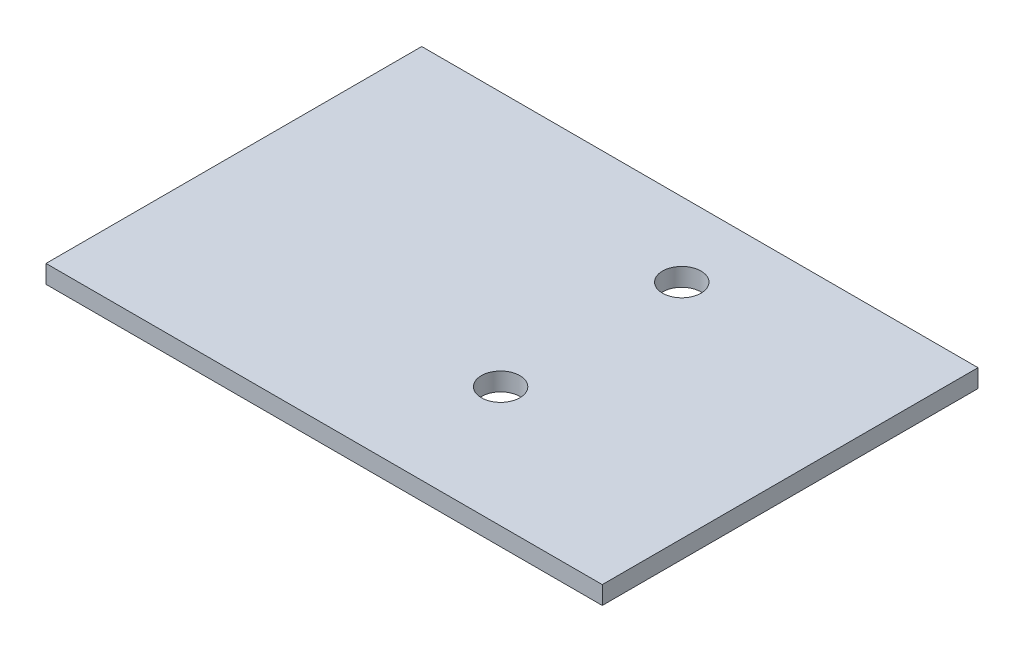
from build123d import *

# Parameters (mm, degrees)
SKETCH1_W           = 49.14
SKETCH1_H           = 33.19
SKETCH1_R           = 1.7
BOSS_EXTRUDE1_DEPTH = 1.6


with BuildPart() as part:
    # Sketch1 → Boss-Extrude1 (new body)
    with BuildSketch(Plane(origin=(0, 0, 0), x_dir=(1, 0, 0), z_dir=(0, 1, 0))):
        Rectangle(SKETCH1_W, SKETCH1_H)
        with Locations((4.94, 10.055)):
            Circle(SKETCH1_R, mode=Mode.SUBTRACT)
        with Locations((4.94, -5.945)):
            Circle(SKETCH1_R, mode=Mode.SUBTRACT)
    extrude(amount=BOSS_EXTRUDE1_DEPTH)


solid = part.part
